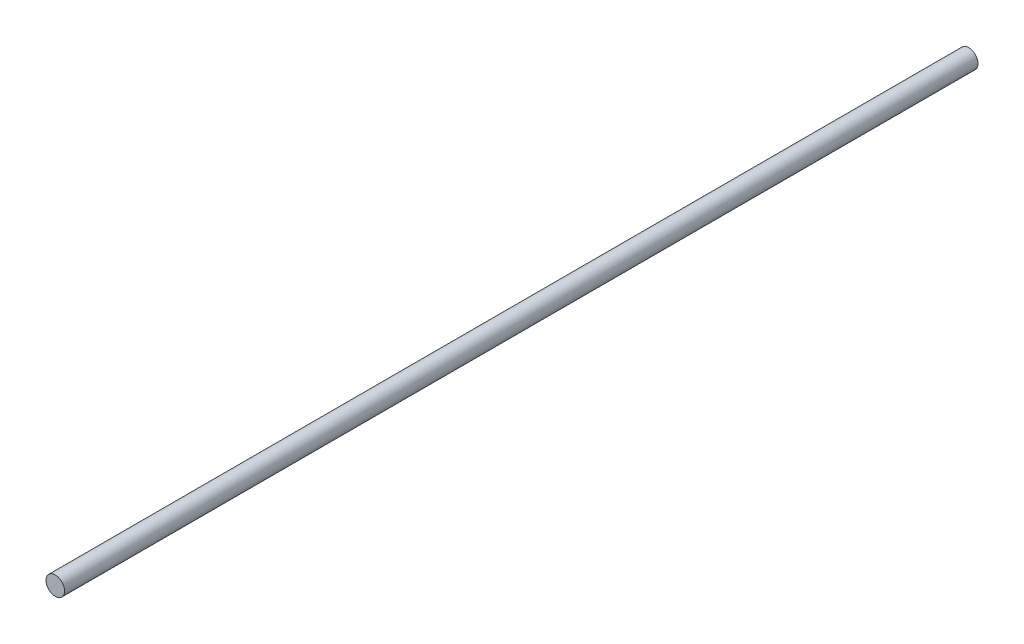
from build123d import *

# Parameters (mm, degrees)
SKETCH1_R           = 3
BOSS_EXTRUDE1_DEPTH = 295


with BuildPart() as part:
    # Sketch1 → Boss-Extrude1 (new body)
    with BuildSketch(Plane.XY):
        Circle(SKETCH1_R)
    extrude(amount=BOSS_EXTRUDE1_DEPTH)


solid = part.part
